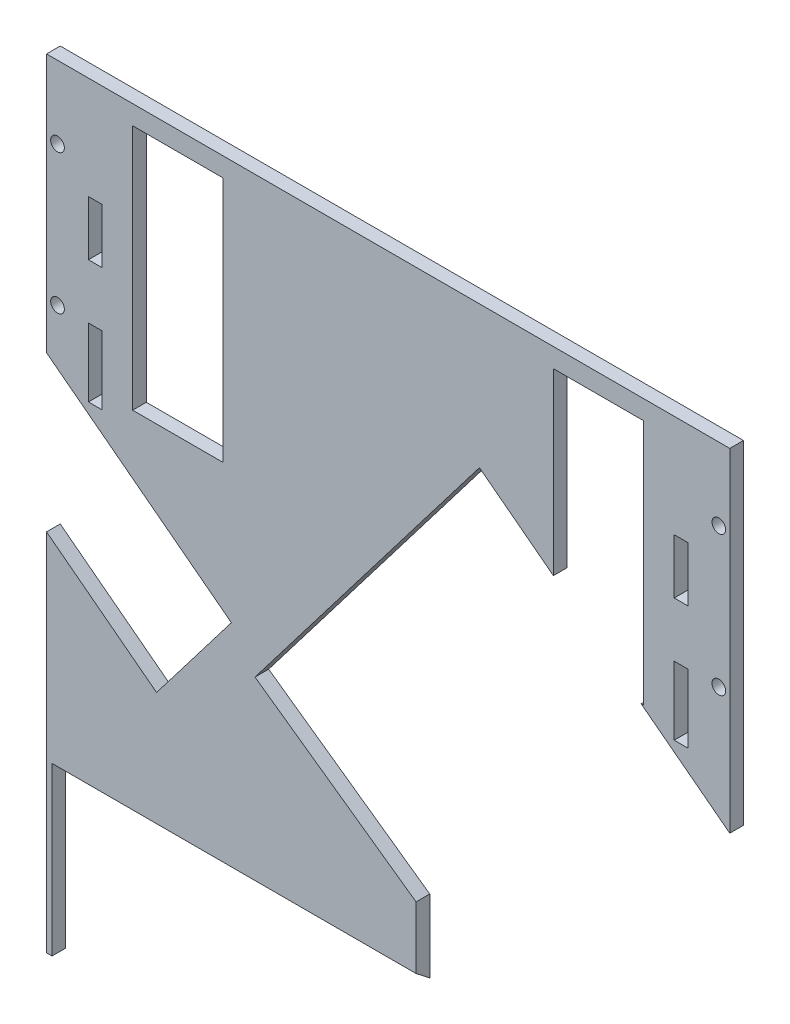
from build123d import *

# Parameters (mm, degrees)
SKETCH1_W           = 249.6
SKETCH1_H           = 284.42
SKETCH1_R           = 2.5
SKETCH1_W_2         = 33
SKETCH1_H_2         = 90
BOSS_EXTRUDE1_DEPTH = 5
SKETCH4_W           = 133
SKETCH4_H           = 244.46665057
CUT_EXTRUDE2_DEPTH  = 49.034766894
CUT_EXTRUDE3_DEPTH  = 6
CUT_EXTRUDE4_DEPTH  = 6
SKETCH7_W           = 5
SKETCH7_H           = 20
SKETCH7_H_2         = 25
CUT_EXTRUDE5_DEPTH  = 6


with BuildPart() as part:
    # Sketch1 → Boss-Extrude1 (new body)
    with BuildSketch(Plane.XY):
        with Locations((124.8, -142.21)):
            Rectangle(SKETCH1_W, SKETCH1_H)
        with Locations((245.6, -26.5)):
            Circle(SKETCH1_R, mode=Mode.SUBTRACT)
        with Locations((245.6, -77.5)):
            Circle(SKETCH1_R, mode=Mode.SUBTRACT)
        with Locations((4, -77.5)):
            Circle(SKETCH1_R, mode=Mode.SUBTRACT)
        with Locations((4, -26.5)):
            Circle(SKETCH1_R, mode=Mode.SUBTRACT)
        with Locations((201.66, -52)):
            Rectangle(SKETCH1_W_2, SKETCH1_H_2, mode=Mode.SUBTRACT)
        with Locations((47.94, -52)):
            Rectangle(SKETCH1_W_2, SKETCH1_H_2, mode=Mode.SUBTRACT)
    extrude(amount=BOSS_EXTRUDE1_DEPTH)

    # Sketch4 → Cut-Extrude2 (cut, through all)
    with BuildSketch(Plane(origin=(0, -141.18753923, 110.307795042), x_dir=(1, 0, 0), z_dir=(0, 0.788010754, -0.615661475))):
        with Locations((68.5, 84.166930672)):
            Rectangle(SKETCH4_W, SKETCH4_H)
    extrude(amount=-CUT_EXTRUDE2_DEPTH, mode=Mode.SUBTRACT)

    # Sketch5 → Cut-Extrude3 (cut, through all)
    with BuildSketch(Plane.XY.offset(5)):
        Polygon((76.149175745, -159.084342324), (158.149444505, -51.841832454), (328.08312673, -181.777318211), (207.31876811, -339.716714228), (135, -284.42), (135, -200.788988557), align=None)
    extrude(amount=-CUT_EXTRUDE3_DEPTH, mode=Mode.SUBTRACT)

    # Sketch6 → Cut-Extrude4 (cut, through all)
    with BuildSketch(Plane.XY.offset(5)):
        Polygon((0, -94.564658056), (67.52306177, -146.194456905), (40.18963885, -181.941960195), (-27.33342292, -130.312161346), align=None)
    extrude(amount=-CUT_EXTRUDE4_DEPTH, mode=Mode.SUBTRACT)

    # Sketch7 → Cut-Extrude5 (cut, through all)
    with BuildSketch(Plane.XY.offset(5)):
        with Locations((17.788155616, -47.477871486)):
            Rectangle(SKETCH7_W, SKETCH7_H)
        with Locations((231.811844384, -47.477871486)):
            Rectangle(SKETCH7_W, SKETCH7_H)
        with Locations((17.788155616, -89.977871486)):
            Rectangle(SKETCH7_W, SKETCH7_H_2)
        with Locations((231.811844384, -89.977871486)):
            Rectangle(SKETCH7_W, SKETCH7_H_2)
    extrude(amount=-CUT_EXTRUDE5_DEPTH, mode=Mode.SUBTRACT)


solid = part.part
